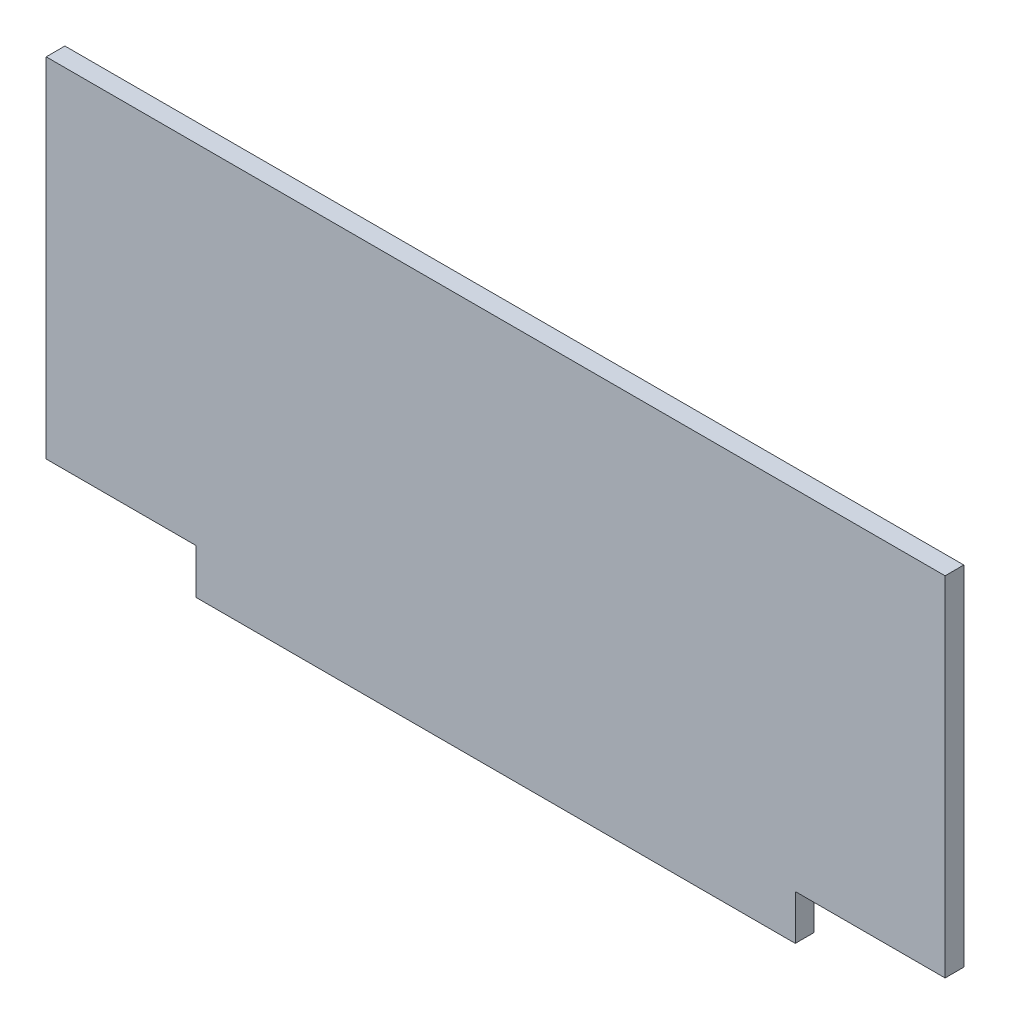
from build123d import *

# Parameters (mm, degrees)
ESQUISSE1_W             = 480
ESQUISSE1_H             = 210
BOSS_EXTRU_1_DEPTH      = 10
ESQUISSE2_W             = 80
ESQUISSE2_H             = 24
ENL_V_MAT_EXTRU_1_DEPTH = 11


with BuildPart() as part:
    # Esquisse1 → Boss.-Extru.1 (new body)
    with BuildSketch(Plane.XY):
        with Locations((-50, 0)):
            Rectangle(ESQUISSE1_W, ESQUISSE1_H)
    extrude(amount=BOSS_EXTRU_1_DEPTH)

    # Esquisse2 → Enlèv. mat.-Extru.1 (cut, through all)
    with BuildSketch(Plane.XY.offset(10)):
        with Locations((150, -93)):
            Rectangle(ESQUISSE2_W, ESQUISSE2_H)
        with Locations((-250, -93)):
            Rectangle(ESQUISSE2_W, ESQUISSE2_H)
    extrude(amount=-ENL_V_MAT_EXTRU_1_DEPTH, mode=Mode.SUBTRACT)


solid = part.part
